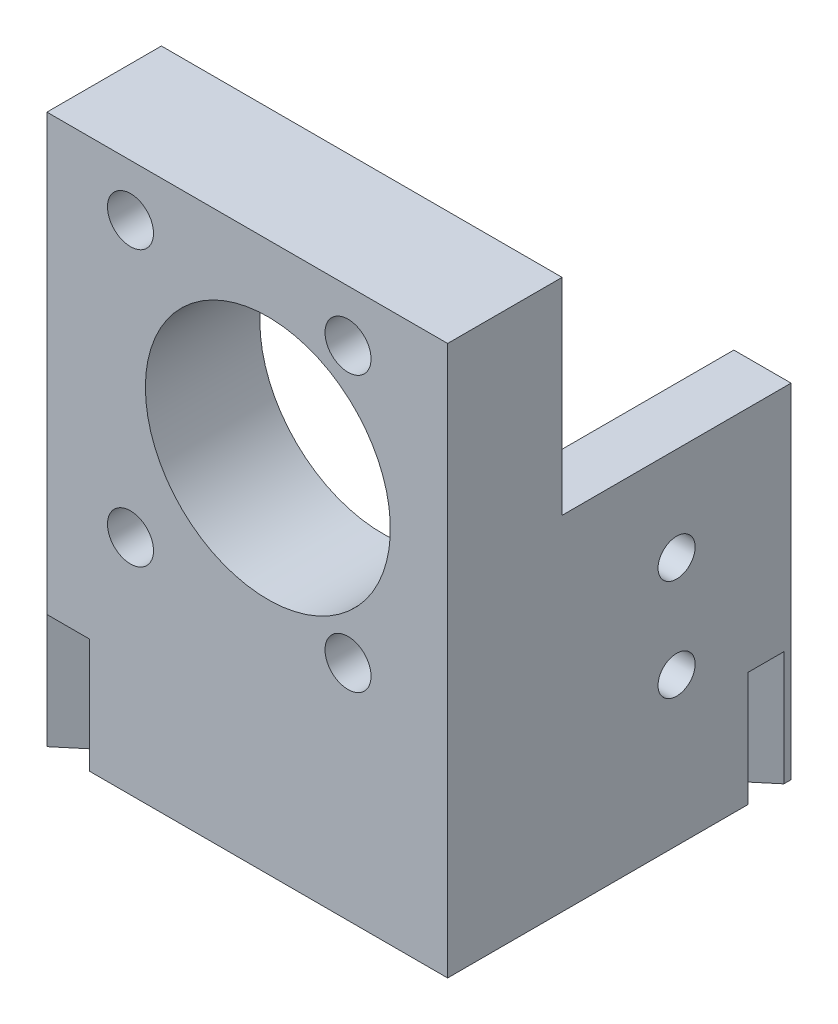
from build123d import *

# Parameters (mm, degrees)
BOSS_EXTRUDE1_DEPTH         = 60.96
SKETCH4_R                   = 2.0574
CUT_EXTRUDE3_DEPTH          = 7.35
SKETCH3_R                   = 13.589
SKETCH3_R_2                 = 2.54
CUT_EXTRUDE2_DEPTH          = 13.7
CUT_EXTRUDE4_DEPTH          = 12.7
SKETCH10_W                  = 6.35
SKETCH10_H                  = 25.4
CUT_EXTRUDE5_DEPTH          = 22.86
F_1_4_20_TAPPED_HOLE1_D     = 5.1054
F_1_4_20_TAPPED_HOLE1_DEPTH = 16.51
F_1_4_20_TAPPED_HOLE1_TIP   = 1.533816902


with BuildPart() as part:
    # Sketch1 → Boss-Extrude1 (new body)
    with BuildSketch(Plane(origin=(0, 0, 0), x_dir=(1, 0, 0), z_dir=(0, 1, 0))):
        Polygon((-44.45, 12.7), (-44.45, 0), (0, 0), (0, 38.1), (-6.35, 38.1), (-6.35, 12.7), align=None)
    extrude(amount=BOSS_EXTRUDE1_DEPTH)

    # Sketch4 → Cut-Extrude3 (cut, through all)
    with BuildSketch(Plane.ZY.offset(6.35)):
        with Locations((-25.4, 16.4338)):
            Circle(SKETCH4_R)
        with Locations((-25.4, 27.686)):
            Circle(SKETCH4_R)
    extrude(amount=-CUT_EXTRUDE3_DEPTH, mode=Mode.SUBTRACT)

    # Sketch3 → Cut-Extrude2 (cut, through all)
    with BuildSketch(Plane(origin=(0, 0, -12.7), x_dir=(-1, 0, 0), z_dir=(0, 0, -1))):
        with Locations((19.939, 39.9796)):
            Circle(SKETCH3_R)
        with Locations((35.179, 55.2196)):
            Circle(SKETCH3_R_2)
        with Locations((11.049, 55.2196)):
            Circle(SKETCH3_R_2)
        with Locations((11.049, 24.7396)):
            Circle(SKETCH3_R_2)
        with Locations((35.179, 24.7396)):
            Circle(SKETCH3_R_2)
    extrude(amount=-CUT_EXTRUDE2_DEPTH, mode=Mode.SUBTRACT)

    # Sketch6 → Cut-Extrude4 (cut)
    with BuildSketch(Plane.XZ):
        Polygon((-47.891108231, 6.866314065), (10.481478335, -42.114101793), (8.522261701, -44.449005256), (-49.850324865, 4.531410602), align=None)
    extrude(amount=-CUT_EXTRUDE4_DEPTH, mode=Mode.SUBTRACT)

    # Sketch10 → Cut-Extrude5 (cut)
    with BuildSketch(Plane(origin=(0, 60.96, 0), x_dir=(1, 0, 0), z_dir=(0, 1, 0))):
        with Locations((-3.175, 25.4)):
            Rectangle(SKETCH10_W, SKETCH10_H)
    extrude(amount=-CUT_EXTRUDE5_DEPTH, mode=Mode.SUBTRACT)

    # 1/4-20 Tapped Hole1
    with Locations(Plane.XY):
        with Locations((-35.179, 55.2196), (-11.049, 55.2196), (-35.179, 24.7396), (-11.049, 24.7396)):
            Hole(F_1_4_20_TAPPED_HOLE1_D / 2, depth=F_1_4_20_TAPPED_HOLE1_DEPTH)
            with Locations((0, 0, -(F_1_4_20_TAPPED_HOLE1_DEPTH + F_1_4_20_TAPPED_HOLE1_TIP / 2))):  # 118° drill point
                Cone(0, F_1_4_20_TAPPED_HOLE1_D / 2, F_1_4_20_TAPPED_HOLE1_TIP, mode=Mode.SUBTRACT)


solid = part.part
